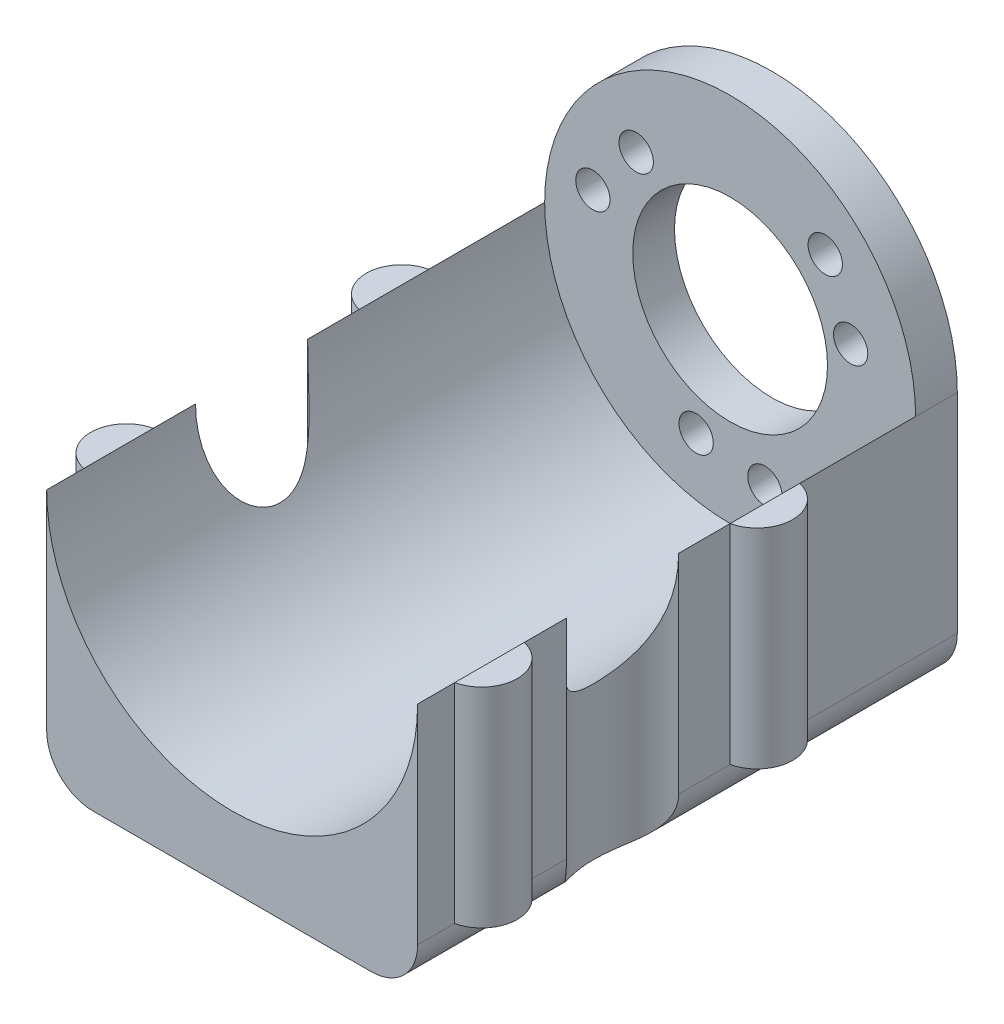
from build123d import *

# Parameters (mm, degrees)
SKETCH3_W           = 40
SKETCH3_H           = 53.7
BOSS_EXTRUDE1_DEPTH = 27.5
BOSS_EXTRUDE4_DEPTH = 27.5
CUT_EXTRUDE1_DEPTH  = 28.5
SKETCH7_R           = 20
CUT_EXTRUDE2_DEPTH  = 54.7
BOSS_EXTRUDE5_DEPTH = 4.5
SKETCH9_R           = 10.5
CUT_EXTRUDE3_DEPTH  = 59.2000001
SKETCH10_R          = 1.85
CUT_EXTRUDE4_DEPTH  = 59.2000001
CUT_EXTRUDE5_DEPTH  = 59.2
CUT_EXTRUDE7_DEPTH  = 59.2000001


with BuildPart() as part:
    # Sketch3 → Boss-Extrude1 (new body)
    with BuildSketch(Plane(origin=(0, 0, 0), x_dir=(1, 0, 0), z_dir=(0, 1, 0))):
        with Locations((20, 26.85)):
            Rectangle(SKETCH3_W, SKETCH3_H)
    extrude(amount=BOSS_EXTRUDE1_DEPTH)

    # Sketch4 → Boss-Extrude4 (add)
    with BuildSketch(Plane(origin=(0, 27.5, 0), x_dir=(1, 0, 0), z_dir=(0, 1, 0))):
        with BuildLine():
            Line((0, 41.2), (0, 33.7))
            ThreePointArc((0, 33.7), (-2.999999474, 37.45), (0, 41.2))
        make_face()
        with BuildLine():
            Line((0, 11.5), (0, 4))
            ThreePointArc((0, 4), (-2.999999474, 7.75), (0, 11.5))
        make_face()
        with BuildLine():
            Line((40, 41.2), (40, 33.7))
            ThreePointArc((40, 33.7), (42.999999474, 37.45), (40, 41.2))
        make_face()
        with BuildLine():
            Line((40, 11.5), (40, 4))
            ThreePointArc((40, 4), (42.999999474, 7.75), (40, 11.5))
        make_face()
    extrude(amount=-BOSS_EXTRUDE4_DEPTH)

    # Sketch6 → Cut-Extrude1 (cut, through all)
    with BuildSketch(Plane(origin=(0, 27.5, 0), x_dir=(1, 0, 0), z_dir=(0, 1, 0))):
        with BuildLine():
            Line((0, 28.15), (0, 16.05))
            ThreePointArc((0, 16.05), (3.100001365, 22.1), (0, 28.15))
        make_face()
        with BuildLine():
            Line((40, 28.15), (40, 16.05))
            ThreePointArc((40, 16.05), (36.899998635, 22.1), (40, 28.15))
        make_face()
    extrude(amount=-CUT_EXTRUDE1_DEPTH, mode=Mode.SUBTRACT)

    # Sketch7 → Cut-Extrude2 (cut, through all)
    with BuildSketch(Plane(origin=(0, 0, -53.7), x_dir=(-1, 0, 0), z_dir=(0, 0, -1))):
        with Locations((-20, 27.5)):
            Circle(SKETCH7_R)
    extrude(amount=-CUT_EXTRUDE2_DEPTH, mode=Mode.SUBTRACT)

    # Sketch8 → Boss-Extrude5 (add)
    with BuildSketch(Plane(origin=(0, 0, -53.7), x_dir=(-1, 0, 0), z_dir=(0, 0, -1))):
        with BuildLine():
            Line((-40, 27.5), (-40, 0))
            Line((-40, 0), (0, 0))
            Line((0, 0), (0, 27.5))
            ThreePointArc((0, 27.5), (-20, 47.5), (-40, 27.5))
        make_face()
    extrude(amount=BOSS_EXTRUDE5_DEPTH)

    # Sketch9 → Cut-Extrude3 (cut, through all)
    with BuildSketch(Plane(origin=(0, 0, -58.2), x_dir=(-1, 0, 0), z_dir=(0, 0, -1))):
        with Locations((-20, 27.5)):
            Circle(SKETCH9_R)
    extrude(amount=-CUT_EXTRUDE3_DEPTH, mode=Mode.SUBTRACT)

    # Sketch10 → Cut-Extrude4 (cut, through all)
    with BuildSketch(Plane(origin=(0, 0, -58.2), x_dir=(-1, 0, 0), z_dir=(0, 0, -1))):
        with Locations((-23.75, 12.9)):
            Circle(SKETCH10_R)
        with Locations((-16.333793604, 14.1)):
            Circle(SKETCH10_R)
        with Locations((-32.995056342, 30.769328778)):
            Circle(SKETCH10_R)
        with Locations((-30.255153544, 37.750942678)):
            Circle(SKETCH10_R)
        with Locations((-9.87, 37.119384527)):
            Circle(SKETCH10_R)
        with Locations((-5.2, 31.25575215)):
            Circle(SKETCH10_R)
    extrude(amount=-CUT_EXTRUDE4_DEPTH, mode=Mode.SUBTRACT)

    # Sketch11 → Cut-Extrude5 (cut, through all)
    with BuildSketch(Plane.XY):
        with BuildLine():
            Line((40, 5), (45.647961317, 5))
            Line((45.647961317, 5), (45.647961317, -3.041494826))
            Line((45.647961317, -3.041494826), (35, -3.041494826))
            Line((35, -3.041494826), (35, 0))
            ThreePointArc((35, 0), (38.535533906, 1.464466094), (40, 5))
        make_face()
    extrude(amount=-CUT_EXTRUDE5_DEPTH, mode=Mode.SUBTRACT)

    # Sketch12 → Cut-Extrude7 (cut, through all)
    with BuildSketch(Plane.XY):
        with BuildLine():
            Line((0, 5), (-3.969490024, 5))
            Line((-3.969490024, 5), (-3.969490024, -1.478021918))
            Line((-3.969490024, -1.478021918), (5, -1.478021918))
            Line((5, -1.478021918), (5, 0))
            ThreePointArc((5, 0), (1.464466094, 1.464466094), (0, 5))
        make_face()
    extrude(amount=-CUT_EXTRUDE7_DEPTH, mode=Mode.SUBTRACT)


solid = part.part
